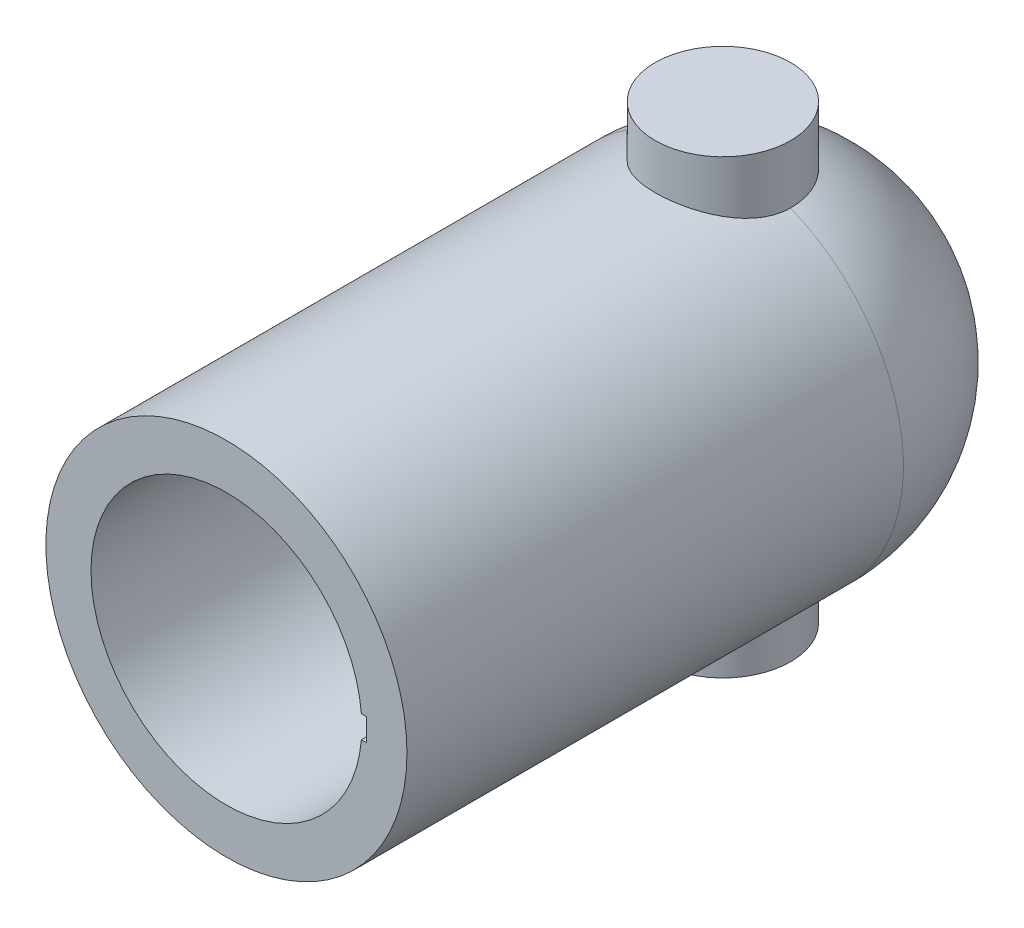
from build123d import *

# Parameters (mm, degrees)
SKETCH1_R           = 40
BOSS_EXTRUDE2_DEPTH = 110
SKETCH4_R           = 15
BOSS_EXTRUDE3_DEPTH = 50
SKETCH5_R           = 15
BOSS_EXTRUDE4_DEPTH = 50
SKETCH6_R           = 30
CUT_EXTRUDE1_DEPTH  = 100
SKETCH8_W           = 31
SKETCH8_H           = 5
CUT_EXTRUDE2_DEPTH  = 100


with BuildPart() as part:
    # Sketch1 → Boss-Extrude2 (new body)
    with BuildSketch(Plane.XY):
        Circle(SKETCH1_R)
    extrude(amount=BOSS_EXTRUDE2_DEPTH)

    # Sketch3 → Revolve1 (revolve)
    with BuildSketch(Plane(origin=(0, 0, 0), x_dir=(0, 0, -1), z_dir=(1, 0, 0))):
        with BuildLine():
            Line((0, 40), (0, -40))
            ThreePointArc((0, -40), (40, 0), (0, 40))
        make_face()
    revolve(axis=Axis((0, -40, 0), (0, 1, 0)))

    # Sketch4 → Boss-Extrude3 (add)
    with BuildSketch(Plane(origin=(0, 0, 0), x_dir=(1, 0, 0), z_dir=(0, 1, 0))):
        Circle(SKETCH4_R)
    extrude(amount=BOSS_EXTRUDE3_DEPTH)

    # Sketch5 → Boss-Extrude4 (add)
    with BuildSketch(Plane(origin=(0, 0, 0), x_dir=(1, 0, 0), z_dir=(0, 1, 0))):
        Circle(SKETCH5_R)
    extrude(amount=-BOSS_EXTRUDE4_DEPTH)

    # Sketch6 → Cut-Extrude1 (cut)
    with BuildSketch(Plane.XY.offset(110)):
        Circle(SKETCH6_R)
    extrude(amount=-CUT_EXTRUDE1_DEPTH, mode=Mode.SUBTRACT)

    # Sketch8 → Cut-Extrude2 (cut)
    with BuildSketch(Plane.XY.offset(110)):
        with Locations((15.5, 0)):
            Rectangle(SKETCH8_W, SKETCH8_H)
    extrude(amount=-CUT_EXTRUDE2_DEPTH, mode=Mode.SUBTRACT)


solid = part.part
